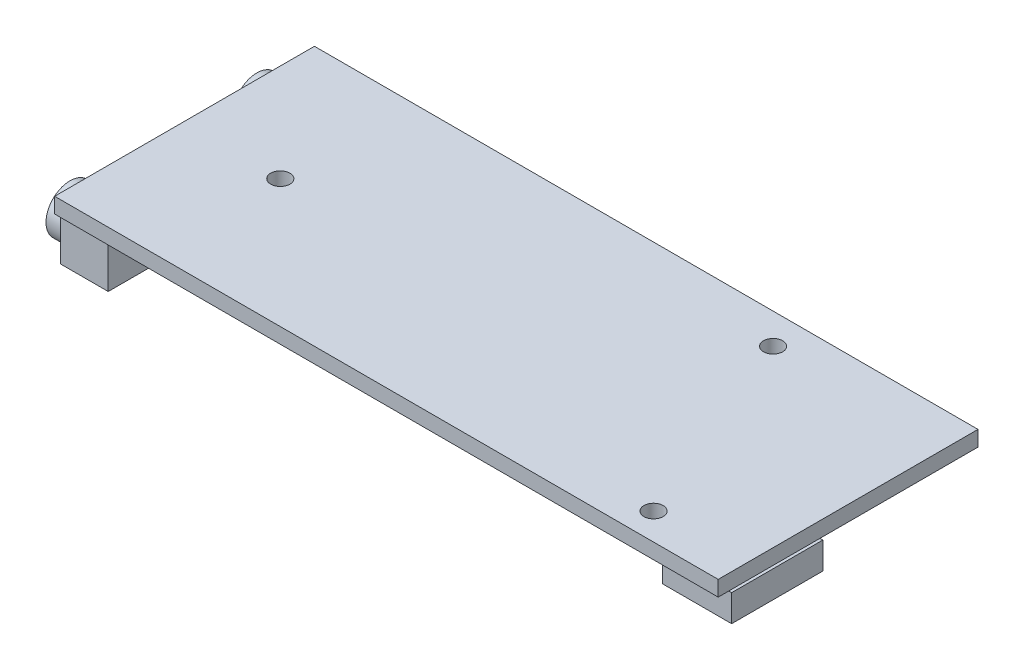
from build123d import *

# Parameters (mm, degrees)
SKETCH1_W           = 69.088
SKETCH1_H           = 27.051
BOSS_EXTRUDE1_DEPTH = 1.6
SKETCH2_W           = 4.978970029
SKETCH2_H           = 6
SKETCH2_W_2         = 3.862002759
SKETCH2_H_2         = 5.859121758
BOSS_EXTRUDE2_DEPTH = 5
SKETCH3_W           = 6.5
SKETCH3_H           = 2.717485229
BOSS_EXTRUDE3_DEPTH = 2
SKETCH4_W           = 7.179475327
SKETCH4_H           = 9.5
BOSS_EXTRUDE4_DEPTH = 2.8
SKETCH5_R           = 1
CUT_EXTRUDE1_DEPTH  = 2.6
SKETCH6_R           = 1.689834655
BOSS_EXTRUDE5_DEPTH = 4
SKETCH7_R           = 0.917545462
BOSS_EXTRUDE6_DEPTH = 4.5
SKETCH8_R           = 2.5
BOSS_EXTRUDE7_DEPTH = 2


with BuildPart() as part:
    # Sketch1 → Boss-Extrude1 (new body)
    with BuildSketch(Plane(origin=(0, 0, 0), x_dir=(1, 0, 0), z_dir=(0, 1, 0))):
        with Locations((34.544, -13.5255)):
            Rectangle(SKETCH1_W, SKETCH1_H)
    extrude(amount=BOSS_EXTRUDE1_DEPTH)

    # Sketch2 → Boss-Extrude2 (add)
    with BuildSketch(Plane(origin=(0, 0, 0), x_dir=(-1, 0, 0), z_dir=(0, -1, 0))):
        with Locations((-2.289485014, -23.251)):
            Rectangle(SKETCH2_W, SKETCH2_H)
        with Locations((-2.289485014, -3.8)):
            Rectangle(SKETCH2_W, SKETCH2_H)
        with Locations((-1.126576215, -14.111503754)):
            Rectangle(SKETCH2_W_2, SKETCH2_H_2)
    extrude(amount=BOSS_EXTRUDE2_DEPTH)

    # Sketch3 → Boss-Extrude3 (add)
    with BuildSketch(Plane(origin=(0, 0, 0), x_dir=(-1, 0, 0), z_dir=(0, -1, 0))):
        with Locations((-60.838, -0.770217549)):
            Rectangle(SKETCH3_W, SKETCH3_H)
    extrude(amount=BOSS_EXTRUDE3_DEPTH)

    # Sketch4 → Boss-Extrude4 (add)
    with BuildSketch(Plane(origin=(0, 0, 0), x_dir=(-1, 0, 0), z_dir=(0, -1, 0))):
        with Locations((-65.798262337, -21.201)):
            Rectangle(SKETCH4_W, SKETCH4_H)
    extrude(amount=BOSS_EXTRUDE4_DEPTH)

    # Sketch5 → Cut-Extrude1 (cut, through all)
    with BuildSketch(Plane(origin=(0, 0, 0), x_dir=(-1, 0, 0), z_dir=(0, -1, 0))):
        with Locations((-59.563, -24.257)):
            Circle(SKETCH5_R)
        with Locations((-50.927, -3.175)):
            Circle(SKETCH5_R)
        with Locations((-10.16, -13.716)):
            Circle(SKETCH5_R)
    extrude(amount=-CUT_EXTRUDE1_DEPTH, mode=Mode.SUBTRACT)

    # Sketch6 → Boss-Extrude5 (add)
    with BuildSketch(Plane(origin=(0, 0, 0), x_dir=(-1, 0, 0), z_dir=(0, -1, 0))):
        with Locations((-59.807454833, -7.251263164)):
            Circle(SKETCH6_R)
    extrude(amount=BOSS_EXTRUDE5_DEPTH)

    # Sketch7 → Boss-Extrude6 (add)
    with BuildSketch(Plane(origin=(0, 0, 0), x_dir=(-1, 0, 0), z_dir=(0, -1, 0))):
        with Locations((-59.438742184, -16.920616946)):
            Circle(SKETCH7_R)
    extrude(amount=BOSS_EXTRUDE6_DEPTH)

    # Sketch8 → Boss-Extrude7 (add)
    with BuildSketch(Plane.ZY.offset(0.2)):
        with Locations((3.8, -2.5)):
            Circle(SKETCH8_R)
        with Locations((23.251, -2.5)):
            Circle(SKETCH8_R)
    extrude(amount=BOSS_EXTRUDE7_DEPTH)


solid = part.part
